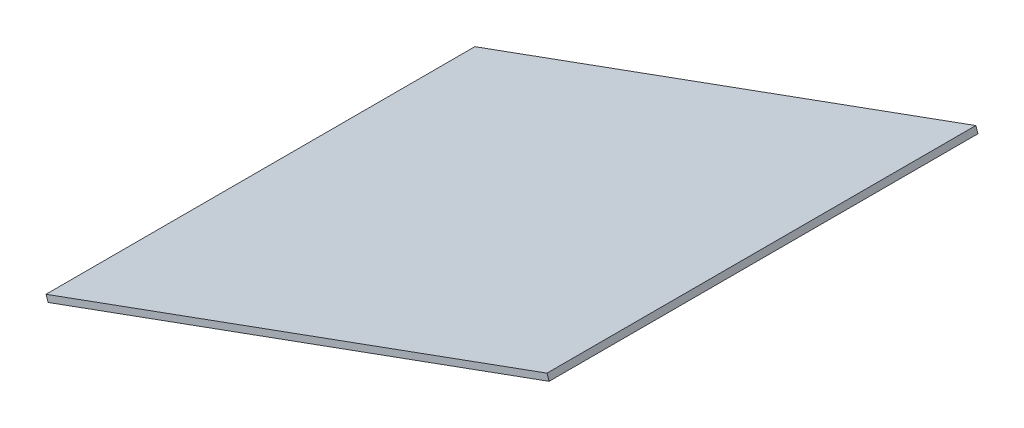
from build123d import *

# Parameters (mm, degrees)
BOSS_EXTRUDE1_DEPTH = 200.8


with BuildPart() as part:
    # Sketch2 → Boss-Extrude1 (new body)
    with BuildSketch(Plane.XY.offset(2)):
        Polygon((9742.340828056, 633.915324322), (9976.911688501, 719.218732404), (9977.936969848, 716.399371101), (9743.366109403, 631.095963019), align=None)
    extrude(amount=BOSS_EXTRUDE1_DEPTH)


solid = part.part
